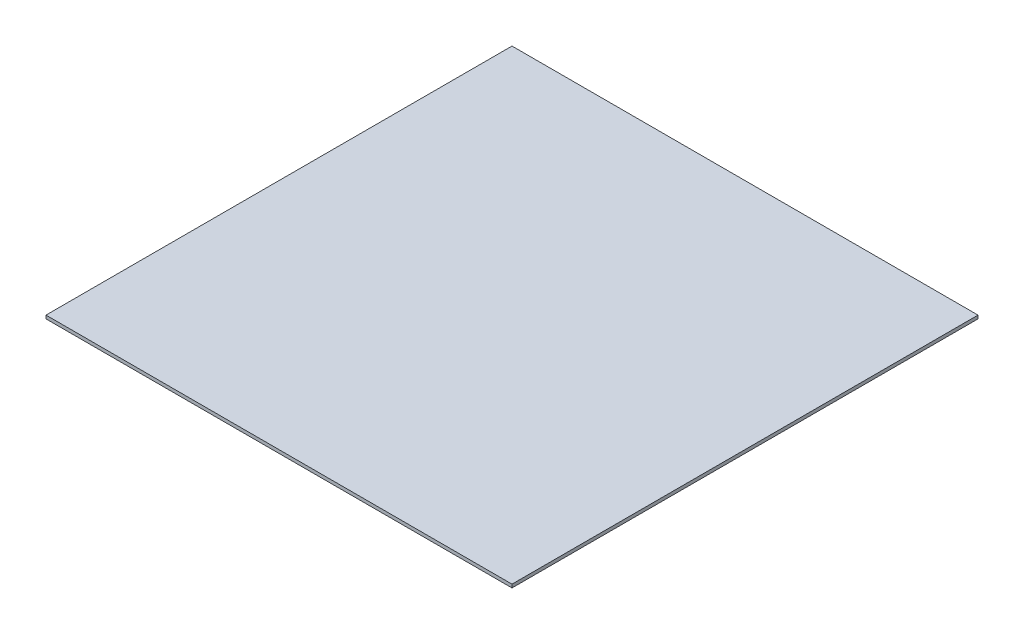
from build123d import *

# Parameters (mm, degrees)
SKETCH1_W           = 107.07
SKETCH1_H           = 107.07
BOSS_EXTRUDE1_DEPTH = 0.762
SCALE2_SCALE        = 0.75


with BuildPart() as part:
    # Sketch1 → Boss-Extrude1 (new body)
    with BuildSketch(Plane(origin=(0, 0, 0), x_dir=(1, 0, 0), z_dir=(0, 1, 0))):
        with Locations((53.535, 53.535)):
            Rectangle(SKETCH1_W, SKETCH1_H)
    extrude(amount=BOSS_EXTRUDE1_DEPTH)


with BuildPart() as part_1:
    # Scale2: scaled about (53.535, 0.381, -53.535)
    add(part.part.scale(SCALE2_SCALE).moved(Location((13.38375, 0.09525, -13.38375))))


solid = part_1.part
